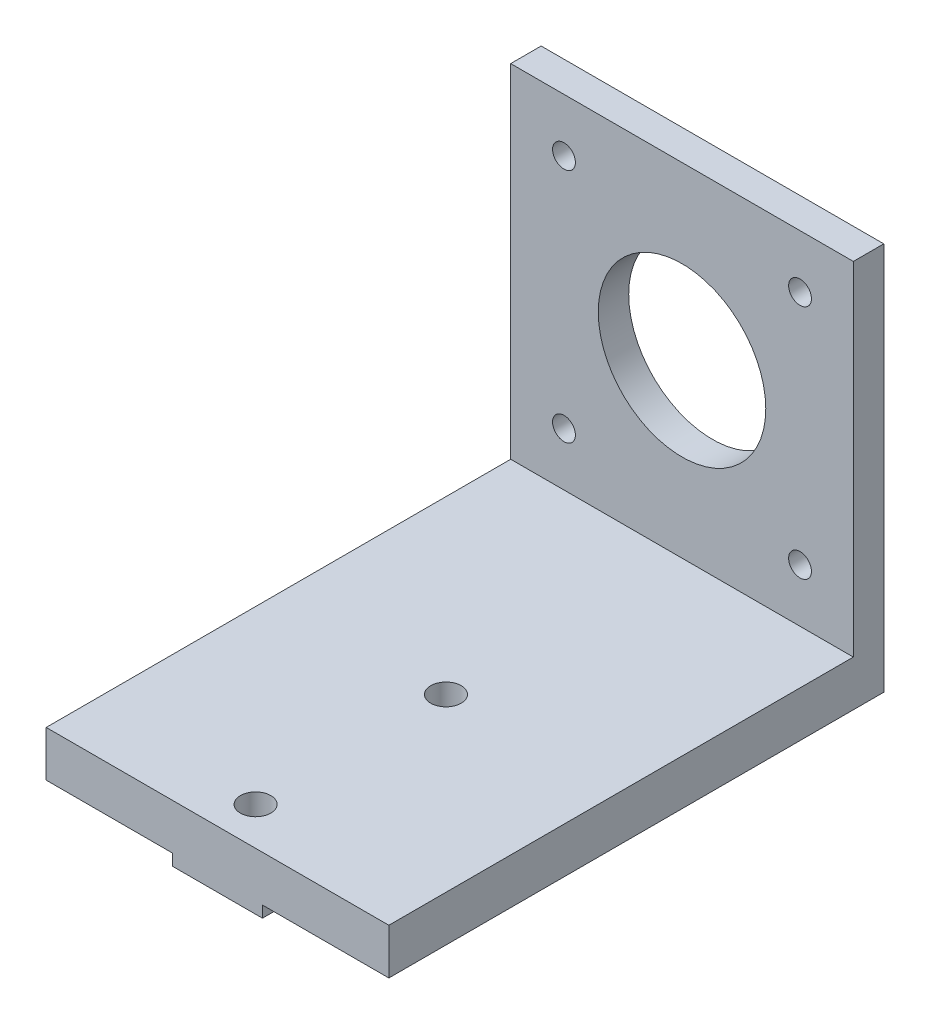
from build123d import *

# Parameters (mm, degrees)
SKETCH1_W           = 45
SKETCH1_H           = 45
SKETCH1_R           = 11
SKETCH1_R_2         = 1.5
BOSS_EXTRUDE1_DEPTH = 4
BOSS_EXTRUDE2_START = 1.649921
SKETCH2_W           = 2.999997759
SKETCH2_H           = 65
SKETCH2_W_2         = 13.199968027
SKETCH2_W_3         = 0.399954884
SKETCH2_W_4         = 11.8
SKETCH2_R           = 2
BOSS_EXTRUDE2_DEPTH = 6
BOSS_EXTRUDE4_START = -4.350079
SKETCH2_5_W         = 11.8
SKETCH2_5_H         = 65
SKETCH2_5_R         = 2
BOSS_EXTRUDE4_DEPTH = 1.5


with BuildPart() as part:
    # Sketch1 → Boss-Extrude1 (new body)
    with BuildSketch(Plane.XY):
        Rectangle(SKETCH1_W, SKETCH1_H)
        Polygon((20.15, -20.15), (20.15, -16.735786438), (20.15, 16.735786438), (16.735786438, 20.15), (-16.735786438, 20.15), (-20.15, 16.735786438), (-20.15, 16.077064234), (-20.15, -16.735786438), (-20.15, -20.15), (-16.735786438, -20.15), (16.735786438, -20.15), align=None, mode=Mode.SUBTRACT)
        Polygon((16.735786438, -20.15), (20.15, -20.15), (20.15, -16.735786438), (20.15, 16.735786438), (16.735786438, 20.15), (-16.735786438, 20.15), (-20.15, 16.735786438), (-20.15, 16.077064234), (-20.15, -16.735786438), (-20.15, -20.15), (-16.735786438, -20.15), align=None)
        Circle(SKETCH1_R, mode=Mode.SUBTRACT)
        with Locations((15.5, -15.5)):
            Circle(SKETCH1_R_2, mode=Mode.SUBTRACT)
        with Locations((15.5, 15.5)):
            Circle(SKETCH1_R_2, mode=Mode.SUBTRACT)
        with Locations((-15.5, -15.5)):
            Circle(SKETCH1_R_2, mode=Mode.SUBTRACT)
        with Locations((-15.5, 15.5)):
            Circle(SKETCH1_R_2, mode=Mode.SUBTRACT)
    extrude(amount=BOSS_EXTRUDE1_DEPTH)

    # Sketch2 → Boss-Extrude2 (add)
    with BuildSketch(Plane(origin=(0, -24.14992067, 0), x_dir=(1, 0, 0), z_dir=(0, 1, 0)).offset(BOSS_EXTRUDE2_START)):
        with Locations((21.000001121, -32.5)):
            Rectangle(SKETCH2_W, SKETCH2_H)
        with Locations((12.900018228, -32.5)):
            Rectangle(SKETCH2_W_2, SKETCH2_H)
        Polygon((-22.5, -65), (-5.89992067, -65), (-5.89992067, 0), (-19.499922911, 0), (-22.5, 0), align=None)
        with Locations((6.100056772, -32.5)):
            Rectangle(SKETCH2_W_3, SKETCH2_H)
        with Locations((7.933e-05, -32.5)):
            Rectangle(SKETCH2_W_4, SKETCH2_H)
        with Locations((-0.001608903, -59.999999943)):
            Circle(SKETCH2_R, mode=Mode.SUBTRACT)
        with Locations((7.933e-05, -35)):
            Circle(SKETCH2_R, mode=Mode.SUBTRACT)
    extrude(amount=-BOSS_EXTRUDE2_DEPTH)

    # Sketch2_5 → Boss-Extrude4 (add)
    with BuildSketch(Plane(origin=(0, -24.14992067, 0), x_dir=(1, 0, 0), z_dir=(0, 1, 0)).offset(BOSS_EXTRUDE4_START)):
        with Locations((7.933e-05, -32.5)):
            Rectangle(SKETCH2_5_W, SKETCH2_5_H)
        with Locations((-0.001608903, -59.999999943)):
            Circle(SKETCH2_5_R, mode=Mode.SUBTRACT)
        with Locations((7.933e-05, -35)):
            Circle(SKETCH2_5_R, mode=Mode.SUBTRACT)
    extrude(amount=-BOSS_EXTRUDE4_DEPTH)


solid = part.part
